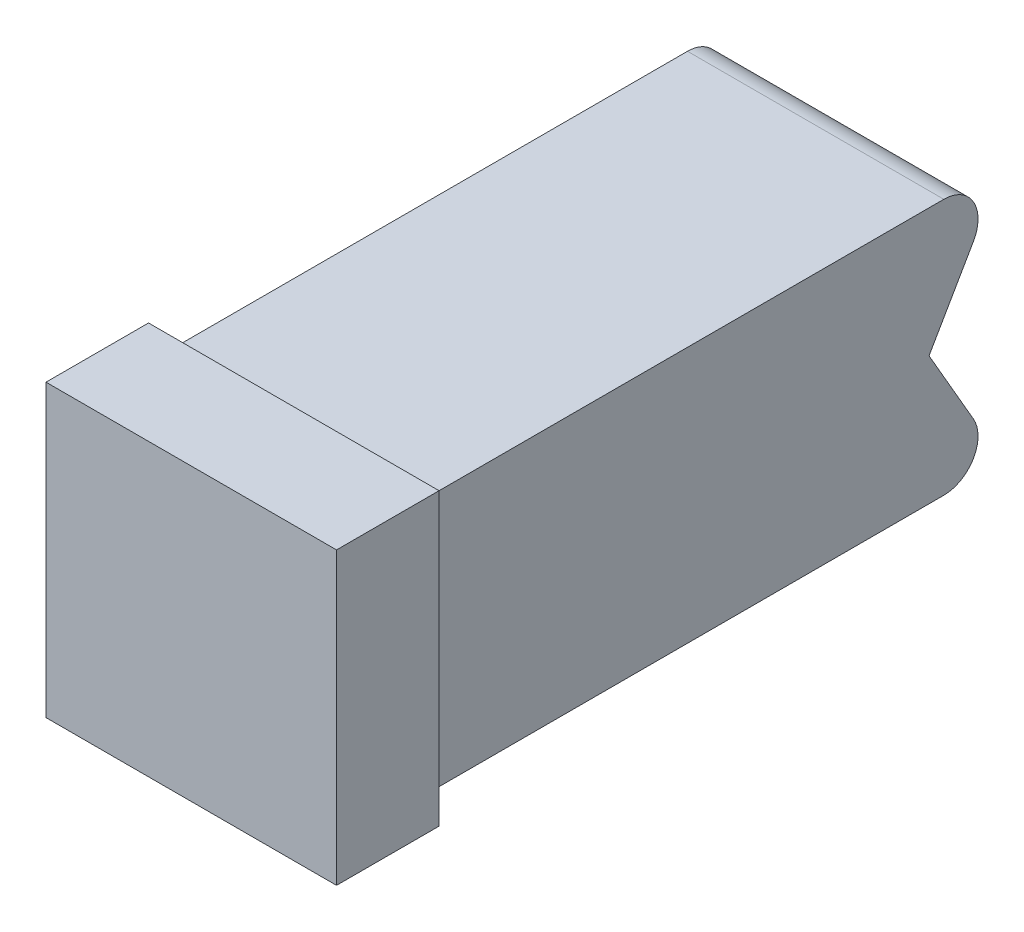
from build123d import *

# Parameters (mm, degrees)
BOSS_EXTRUDE1_DEPTH = 7.5
SKETCH2_W           = 7.5
SKETCH2_H           = 18.267949192
BOSS_EXTRUDE2_DEPTH = 0.5
SKETCH3_W           = 18.267949192
SKETCH3_H           = 8
BOSS_EXTRUDE3_DEPTH = 0.5
SKETCH4_W           = 8
SKETCH4_H           = 18.267949192
BOSS_EXTRUDE4_DEPTH = 0.5
CUT_EXTRUDE1_DEPTH  = 0.433012702
CUT_EXTRUDE2_DEPTH  = 14.834936491
SKETCH7_W           = 3
SKETCH7_H           = 8.5
BOSS_EXTRUDE5_DEPTH = 0.5


with BuildPart() as part:
    # Sketch1 → Boss-Extrude1 (new body)
    with BuildSketch(Plane(origin=(0.5, 0, 0), x_dir=(0, -1, 0), z_dir=(-1, 0, 0))):
        with BuildLine():
            Line((-0.5, 3), (-8, 3))
            Line((-8, 3), (-8, -15.267949192))
            ThreePointArc((-8, -15.267949192), (-7.5, -16.133974596), (-6.5, -16.133974596))
            Line((-6.5, -16.133974596), (-4.25, -14.834936491))
            Line((-4.25, -14.834936491), (-2, -16.133974596))
            ThreePointArc((-2, -16.133974596), (-1, -16.133974596), (-0.5, -15.267949192))
            Line((-0.5, -15.267949192), (-0.5, 3))
        make_face()
    extrude(amount=-BOSS_EXTRUDE1_DEPTH)

    # Sketch2 → Boss-Extrude2 (add)
    with BuildSketch(Plane(origin=(0, 8, 0), x_dir=(-1, 0, 0), z_dir=(0, 1, 0))):
        with Locations((-4.25, -6.133974596)):
            Rectangle(SKETCH2_W, SKETCH2_H)
    extrude(amount=BOSS_EXTRUDE2_DEPTH)

    # Sketch3 → Boss-Extrude3 (add)
    with BuildSketch(Plane(origin=(8, 0, 0), x_dir=(0, 0, -1), z_dir=(1, 0, 0))):
        with Locations((6.133974596, 4.5)):
            Rectangle(SKETCH3_W, SKETCH3_H)
    extrude(amount=BOSS_EXTRUDE3_DEPTH)

    # Sketch4 → Boss-Extrude4 (add)
    with BuildSketch(Plane.XZ.offset(-0.5)):
        with Locations((4.5, -6.133974596)):
            Rectangle(SKETCH4_W, SKETCH4_H)
    extrude(amount=BOSS_EXTRUDE4_DEPTH)

    # Sketch5 → Cut-Extrude1 (cut)
    with BuildSketch(Plane(origin=(0, 0, -15.267949192), x_dir=(-1, 0, 0), z_dir=(0, 0, -1))):
        Polygon((-0.5, 8), (-0.5, 8.5), (-8.5, 8.5), (-8.5, 0), (-0.5, 0), (-0.5, 0.5), (-8, 0.5), (-8, 4.25), (-8, 8), align=None)
    extrude(amount=-CUT_EXTRUDE1_DEPTH, mode=Mode.SUBTRACT)

    # Sketch6 → Cut-Extrude2 (cut)
    with BuildSketch(Plane(origin=(0, 0, -14.834936491), x_dir=(-1, 0, 0), z_dir=(0, 0, -1))):
        Polygon((-0.5, 8), (-0.5, 8.5), (-8.5, 8.5), (-8.5, 0), (-0.5, 0), (-0.5, 0.5), (-8, 0.5), (-8, 8), align=None)
    extrude(amount=-CUT_EXTRUDE2_DEPTH, mode=Mode.SUBTRACT)

    # Sketch7 → Boss-Extrude5 (add)
    with BuildSketch(Plane.ZY.offset(-0.5)):
        with Locations((1.5, 4.25)):
            Rectangle(SKETCH7_W, SKETCH7_H)
    extrude(amount=BOSS_EXTRUDE5_DEPTH)


solid = part.part
